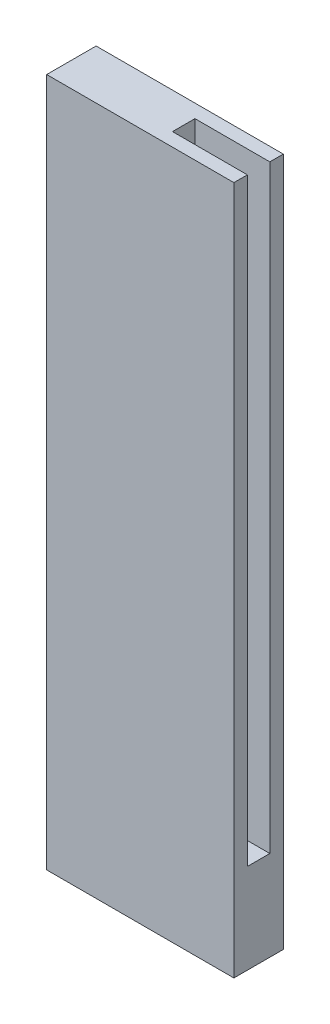
from build123d import *

# Parameters (mm, degrees)
SKETCH1_W           = 125
SKETCH1_H           = 460
BOSS_EXTRUDE1_DEPTH = 33
SKETCH2_W           = 50
SKETCH2_H           = 15
CUT_EXTRUDE1_DEPTH  = 400


with BuildPart() as part:
    # Sketch1 → Boss-Extrude1 (new body)
    with BuildSketch(Plane.XY):
        with Locations((-62.5, -230)):
            Rectangle(SKETCH1_W, SKETCH1_H)
    extrude(amount=BOSS_EXTRUDE1_DEPTH)

    # Sketch2 → Cut-Extrude1 (cut)
    with BuildSketch(Plane(origin=(0, 0, 0), x_dir=(1, 0, 0), z_dir=(0, 1, 0))):
        with Locations((-25, -16.5)):
            Rectangle(SKETCH2_W, SKETCH2_H)
    extrude(amount=-CUT_EXTRUDE1_DEPTH, mode=Mode.SUBTRACT)


solid = part.part
